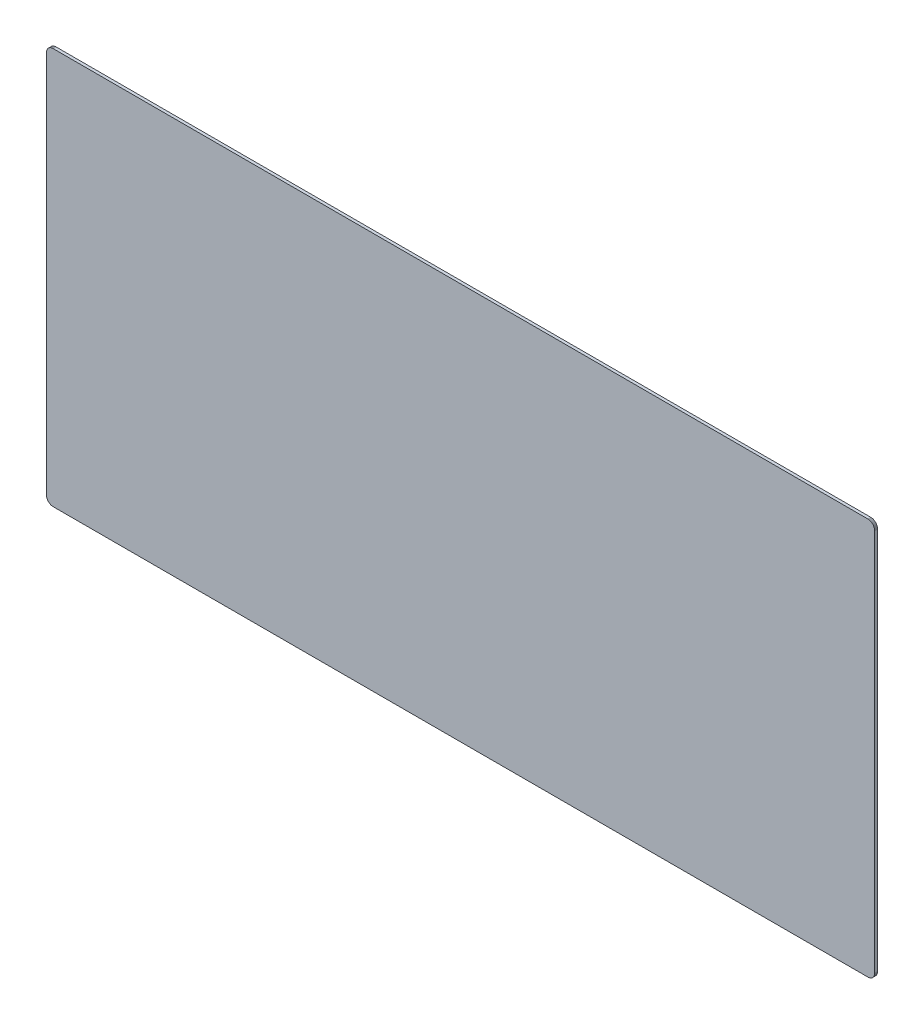
from build123d import *

# Parameters (mm, degrees)
EXTRUDE_1_DEPTH = 1.3


with BuildPart() as part:
    # Model → 凸台-拉伸1 (new body)
    with BuildSketch(Plane.XY):
        Polygon((364.568, 176.294), (364.804, 176.284), (365.037, 176.258), (365.27, 176.211), (365.495, 176.148), (365.718, 176.065), (365.933, 175.967), (366.134, 175.852), (366.332, 175.722), (366.518, 175.576), (366.688, 175.416), (366.85, 175.242), (366.995, 175.058), (367.125, 174.862), (367.242, 174.655), (367.34, 174.442), (367.422, 174.221), (367.485, 173.994), (367.531, 173.764), (367.559, 173.53), (367.57, 173.294), (367.57, 3.27284), (367.559, 3.0372), (367.531, 2.80293), (367.485, 2.5728), (367.422, 2.34542), (367.34, 2.12494), (367.242, 1.91134), (367.125, 1.70601), (366.995, 1.50895), (366.85, 1.3243), (366.688, 1.15204), (366.518, 0.990808), (366.332, 0.844737), (366.134, 0.7152), (365.933, 0.599447), (365.718, 0.501608), (365.495, 0.418924), (365.27, 0.355533), (365.037, 0.310059), (364.804, 0.282498), (364.568, 0.272852), (3.09507, 0.272852), (2.85943, 0.282498), (2.62516, 0.310059), (2.39503, 0.355533), (2.16765, 0.418924), (1.94717, 0.501608), (1.73357, 0.599447), (1.52687, 0.7152), (1.33119, 0.844737), (1.14653, 0.990808), (0.972894, 1.15204), (0.813043, 1.3243), (0.666972, 1.50895), (0.537436, 1.70601), (0.421679, 1.91134), (0.323839, 2.12494), (0.241157, 2.34542), (0.177767, 2.5728), (0.130914, 2.80293), (0.104731, 3.0372), (0.0950846, 3.27284), (0.0950846, 173.294), (0.104731, 173.53), (0.130914, 173.764), (0.177767, 173.994), (0.241157, 174.221), (0.323839, 174.442), (0.421679, 174.655), (0.537436, 174.862), (0.666972, 175.058), (0.813043, 175.242), (0.972894, 175.416), (1.14653, 175.576), (1.33119, 175.722), (1.52687, 175.852), (1.73357, 175.967), (1.94717, 176.065), (2.16765, 176.148), (2.39503, 176.211), (2.62516, 176.258), (2.85943, 176.284), (3.09507, 176.294), align=None)
    extrude(amount=EXTRUDE_1_DEPTH)


solid = part.part
